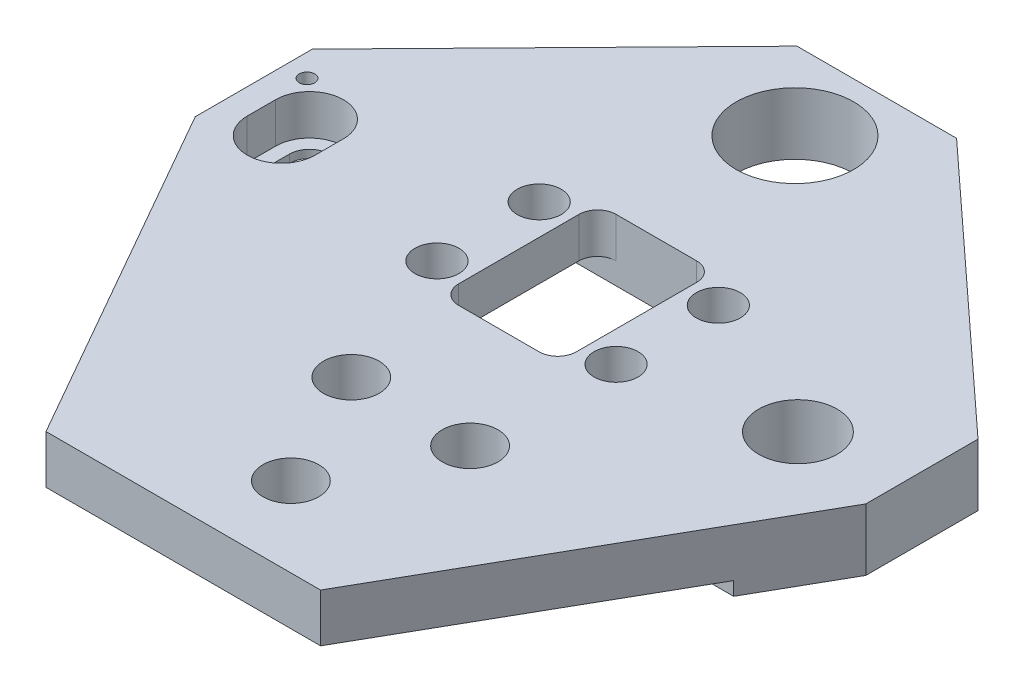
from build123d import *

# Parameters (mm, degrees)
SKETCH1_W           = 19
SKETCH1_H           = 25.42
BOSS_EXTRUDE2_DEPTH = 10
FILLET1_R           = 3
SKETCH3_W           = 19.1
SKETCH3_H           = 2.2
CUT_EXTRUDE2_DEPTH  = 127.977650002
SKETCH4_R           = 6.33
SKETCH4_R_2         = 3.55
SKETCH4_R_3         = 4.5
SKETCH4_R_4         = 9.475
SKETCH4_R_5         = 1.25
CUT_EXTRUDE3_DEPTH  = 81.239939075
SKETCH5_W           = 42.44
SKETCH5_H           = 2.2
CUT_EXTRUDE4_DEPTH  = 108.006765313
SKETCH6_W           = 39.39
SKETCH6_H           = 25.42
CUT_EXTRUDE5_DEPTH  = 3.5
FILLET2_R           = 2
CUT_EXTRUDE6_DEPTH  = 6.5
CUT_EXTRUDE7_DEPTH  = 80.879270294


with BuildPart() as part:
    # Sketch1 → Boss-Extrude2 (new body)
    with BuildSketch(Plane(origin=(0, 0, 0), x_dir=(1, 0, 0), z_dir=(0, 1, 0))):
        Polygon((54.1, 18.1), (54.1, 0), (22.15, -56.030772795), (-22.15, -56.030772795), (-54.1, 0), (-54.1, 18.89218031), (-15.415468147, 58.409227205), (10.334531853, 58.409227205), align=None)
        with Locations((0, 7.599227205)):
            Rectangle(SKETCH1_W, SKETCH1_H, mode=Mode.SUBTRACT)
    extrude(amount=BOSS_EXTRUDE2_DEPTH)

    # Fillet1
    fillet1_edges = [part.edges().sort_by_distance(p)[0] for p in [
        (-9.5, 5, 5.110772795),
        (9.5, 5, 5.110772795),
        (9.5, 5, -20.309227205),
        (-9.5, 5, -20.309227205),
    ]]
    fillet(fillet1_edges, radius=FILLET1_R)

    # Sketch3 → Cut-Extrude2 (cut, through all)
    with BuildSketch(Plane(origin=(0, 0, -58.409227205), x_dir=(-1, 0, 0), z_dir=(0, 0, -1))):
        with Locations((44.55, 1.1)):
            Rectangle(SKETCH3_W, SKETCH3_H)
    extrude(amount=-CUT_EXTRUDE2_DEPTH, mode=Mode.SUBTRACT)

    # Sketch4 → Cut-Extrude3 (cut, through all)
    with BuildSketch(Plane(origin=(0, 10, 0), x_dir=(1, 0, 0), z_dir=(0, 1, 0))):
        with Locations((38.535, 4.609227205)):
            Circle(SKETCH4_R)
        with Locations((-14.45, -0.650772795)):
            Circle(SKETCH4_R_2)
        with Locations((-14.45, 15.849227205)):
            Circle(SKETCH4_R_2)
        with Locations((14.45, -0.650772795)):
            Circle(SKETCH4_R_2)
        with Locations((14.45, 15.849227205)):
            Circle(SKETCH4_R_2)
        with Locations((-5.105, -23.816239571)):
            Circle(SKETCH4_R_3)
        with Locations((14.065, -23.816239571)):
            Circle(SKETCH4_R_3)
        with Locations((4.48, -43.150772795)):
            Circle(SKETCH4_R_3)
        with Locations((-3.065, 45.734227205)):
            Circle(SKETCH4_R_4)
        with Locations((-50.45, 14.379227205)):
            Circle(SKETCH4_R_5)
    extrude(amount=-CUT_EXTRUDE3_DEPTH, mode=Mode.SUBTRACT)

    # Sketch5 → Cut-Extrude4 (cut, through all)
    with BuildSketch(Plane.ZY.offset(35)):
        with Locations((34.810772795, 1.1)):
            Rectangle(SKETCH5_W, SKETCH5_H)
    extrude(amount=-CUT_EXTRUDE4_DEPTH, mode=Mode.SUBTRACT)

    # Sketch6 → Cut-Extrude5 (cut)
    with BuildSketch(Plane.XZ):
        with Locations((0, -7.599227205)):
            Rectangle(SKETCH6_W, SKETCH6_H)
    extrude(amount=-CUT_EXTRUDE5_DEPTH, mode=Mode.SUBTRACT)

    # Fillet2
    fillet2_edges = [part.edges().sort_by_distance(p)[0] for p in [
        (19.695, 1.75, 5.110772795),
        (19.695, 1.75, -20.309227205),
        (-19.695, 1.75, 5.110772795),
        (-19.695, 1.75, -20.309227205),
    ]]
    fillet(fillet2_edges, radius=FILLET2_R)

    # Sketch4_3 → Cut-Extrude6 (cut)
    with BuildSketch(Plane(origin=(0, 10, 0), x_dir=(1, 0, 0), z_dir=(0, 1, 0))):
        with BuildLine():
            Line((-39.06, 4.289227205), (-39.06, 8.869227205))
            ThreePointArc((-39.06, 8.869227205), (-44.53, 14.339227205), (-50, 8.869227205))
            Line((-50, 8.869227205), (-50, 4.289227205))
            ThreePointArc((-50, 4.289227205), (-44.53, -1.180772795), (-39.06, 4.289227205))
        make_face()
    extrude(amount=-CUT_EXTRUDE6_DEPTH, mode=Mode.SUBTRACT)

    # Sketch7 → Cut-Extrude7 (cut, through all)
    with BuildSketch(Plane(origin=(0, 3.5, 0), x_dir=(-1, 0, 0), z_dir=(0, 1, 0))):
        with BuildLine():
            Line((41.28, -8.869227205), (41.28, -4.289227205))
            ThreePointArc((41.28, -4.289227205), (44.53, -1.039227205), (47.78, -4.289227205))
            Line((47.78, -4.289227205), (47.78, -8.869227205))
            ThreePointArc((47.78, -8.869227205), (44.53, -12.119227205), (41.28, -8.869227205))
        make_face()
    extrude(amount=-CUT_EXTRUDE7_DEPTH, mode=Mode.SUBTRACT)


solid = part.part
